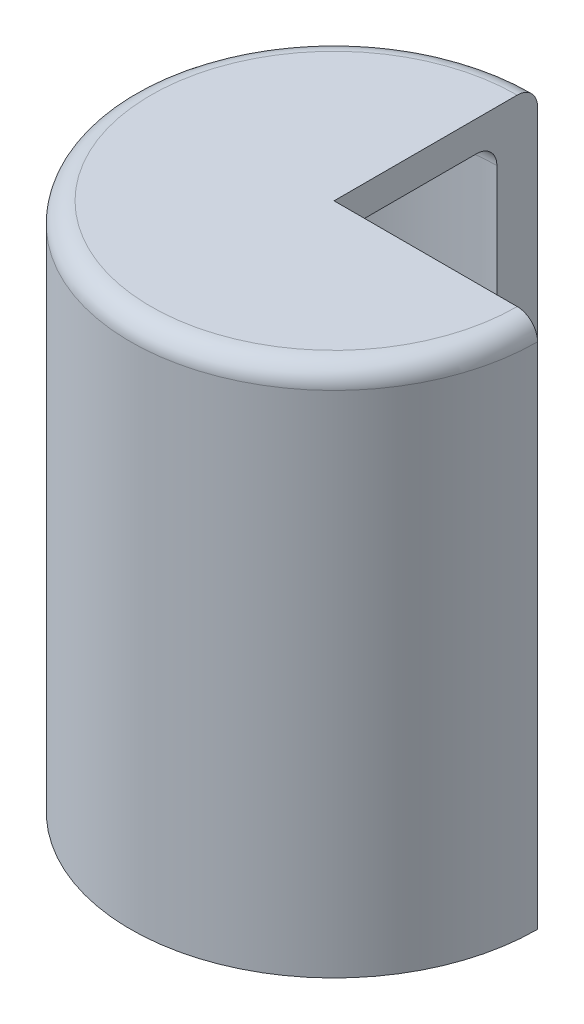
from build123d import *

# Parameters (mm, degrees)
REVOLVE1_ANGLE = 270


with BuildPart() as part:
    # Sketch1 → Revolve1 (revolve)
    with BuildSketch(Plane.XY):
        with BuildLine():
            Line((0, 40.288428911), (70, 40.288428911))
            ThreePointArc((70, 40.288428911), (77.071067812, 37.359496723), (80, 30.288428911))
            Line((80, 30.288428911), (80, -204.742322884))
            Line((80, -204.742322884), (100, -204.742322884))
            Line((100, -204.742322884), (100, 45.257677116))
            ThreePointArc((100, 45.257677116), (97.071067812, 52.328744927), (90, 55.257677116))
            Line((90, 55.257677116), (0, 55.257677116))
            Line((0, 55.257677116), (0, 40.288428911))
        make_face()
    revolve(axis=Axis((0, 40.288428911, 0), (0, -1, 0)), revolution_arc=REVOLVE1_ANGLE)


solid = part.part
